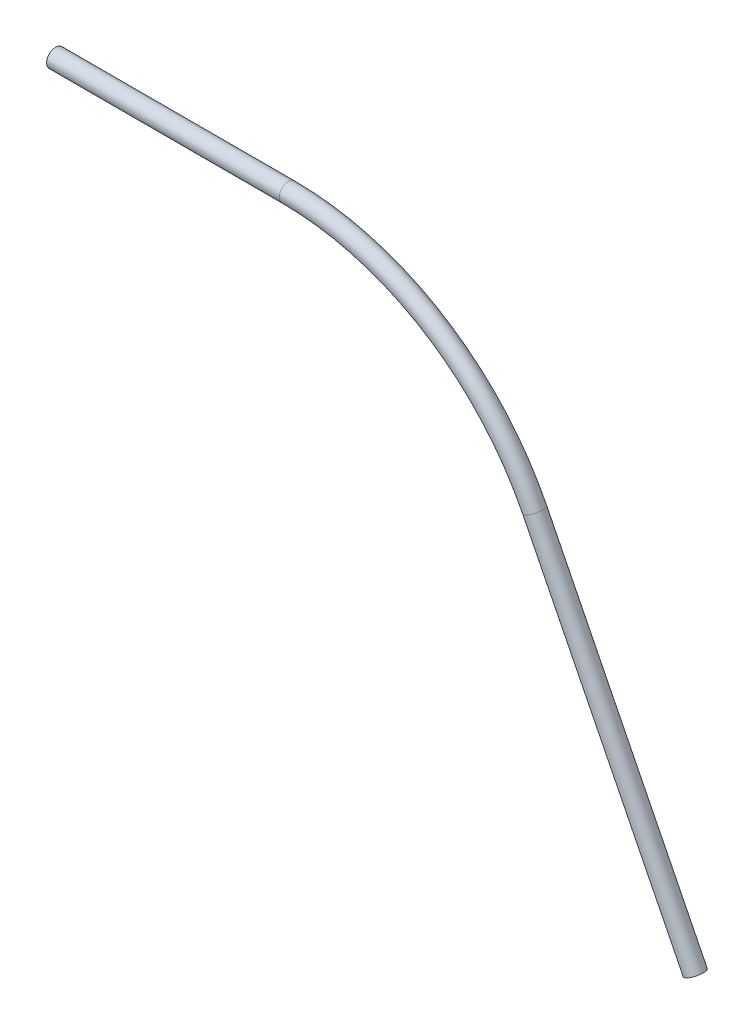
from build123d import *

# Parameters (mm, degrees)
SKETCH1_R   = 0.62
SKETCH1_R_2 = 0.498


with BuildPart() as part:
    # Sweep1: sweep along a path in Sketch2
    with BuildLine(Plane.XY) as sweep1_path:
        Line((0, 0), (16.045517383, 0))
        ThreePointArc((16.045517383, 0), (26.028360553, -2.83389836), (33.033270787, -10.490227132))
        Line((33.033270787, -10.490227132), (44.102671455, -32.587673422))
    # Sketch1 → Sweep1 (sweep)
    with BuildSketch(Plane(origin=(0, 0, 0), x_dir=(0, 0, -1), z_dir=(1, 0, 0))):
        Circle(SKETCH1_R)
        Circle(SKETCH1_R_2, mode=Mode.SUBTRACT)
    sweep(path=sweep1_path.line)


solid = part.part
